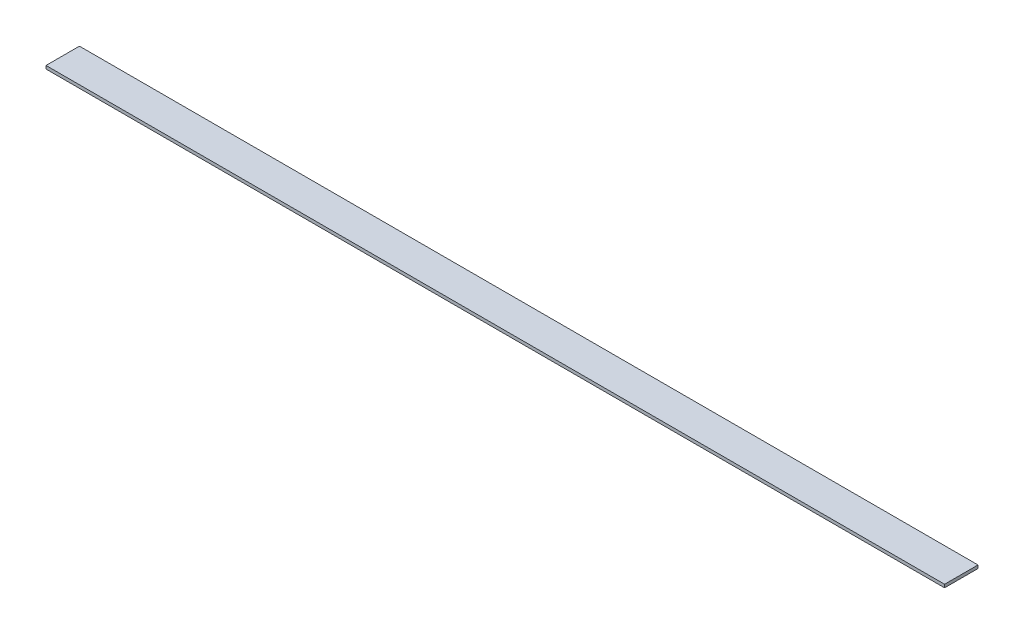
from build123d import *

# Parameters (mm, degrees)
SKETCH1_W           = 430
SKETCH1_H           = 16
BOSS_EXTRUDE1_DEPTH = 1.5


with BuildPart() as part:
    # Sketch1 → Boss-Extrude1 (new body)
    with BuildSketch(Plane(origin=(0, 0, 0), x_dir=(1, 0, 0), z_dir=(0, 1, 0))):
        Rectangle(SKETCH1_W, SKETCH1_H)
    extrude(amount=BOSS_EXTRUDE1_DEPTH)


solid = part.part
